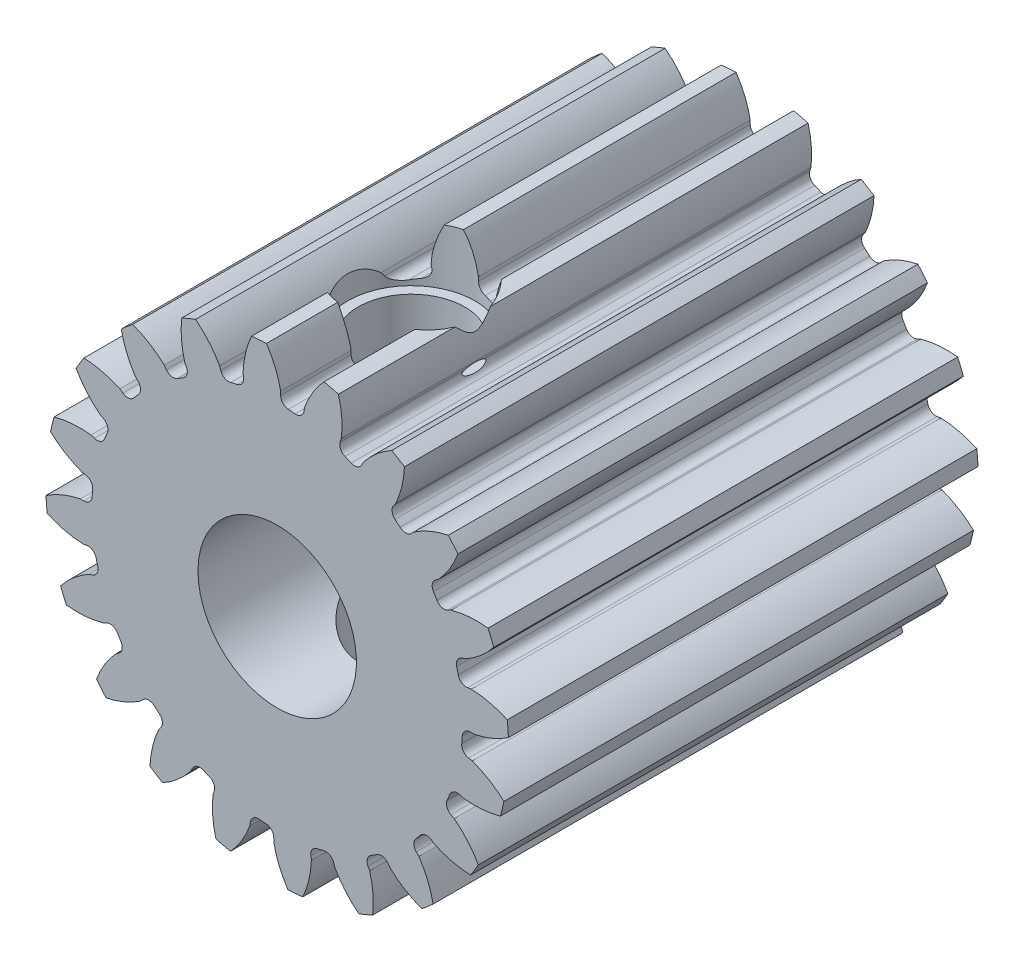
from build123d import *

# Parameters (mm, degrees)
SKETCH1_R                = 8.763
BOSS_EXTRUDE1_DEPTH      = 304.8
CUT_EXTRUDE1_DEPTH       = 305.8
FILLET1_R                = 0.311705625
CIRPATTERN1_COUNT        = 20
FILLET1_OF_CIRPATTERN1_R = 0.311705625
CUT_EXTRUDE2_START       = 6.604
SKETCH6_R                = 2.413
CUT_EXTRUDE2_DEPTH       = 3.149595983
F_10_32_TAPPED_HOLE1_D   = 4.0386


with BuildPart() as part:
    # Sketch1 → Boss-Extrude1 (new body)
    with BuildSketch(Plane.XY):
        Circle(SKETCH1_R)
    extrude(amount=-BOSS_EXTRUDE1_DEPTH)

    # Sketch4 → Cut-Extrude1 (cut, through all)
    with BuildSketch(Plane.XY):
        with BuildLine():
            Line((0.129659117, 7.457683137), (0.129659117, 7.0179336))
            ThreePointArc((0.129659117, 7.0179336), (0.550715976, 6.99749351), (0.969786444, 6.95181399))
            Line((0.969786444, 6.95181399), (1.038578587, 7.386149456))
            add(Edge.make_bspline(
                [(2.617270175, 9.278720795), (1.469881899, 8.555671015), (1.038578587, 7.386149456)],
                knots=[0, 0, 0, 1, 1, 1], degree=2))
            ThreePointArc((2.617270175, 9.278720795), (0.75640915, 9.611066952), (-1.133531995, 9.573916021))
            add(Edge.make_bspline(
                [(-1.133531995, 9.573916021), (-0.113380207, 8.680276738), (0.129659117, 7.457683137)],
                knots=[0, 0, 0, 1, 1, 1], degree=2))
        make_face()
    cut_extrude1 = extrude(amount=-CUT_EXTRUDE1_DEPTH, mode=Mode.SUBTRACT)

    # Fillet1
    fillet1_edges = [part.edges().sort_by_distance(p)[0] for p in [
        (0.969786444, 6.95181399, -152.4),
        (0.129659117, 7.0179336, -152.4),
    ]]
    fillet(fillet1_edges, radius=FILLET1_R)

    # CirPattern1: Cut-Extrude1 ×20 about axis
    cirpattern1_axis = Axis((0, 0, -304.8), (0, 0, 1))
    for i in range(1, CIRPATTERN1_COUNT):
        add(cut_extrude1.rotate(cirpattern1_axis, i * 360 / CIRPATTERN1_COUNT), mode=Mode.SUBTRACT)

    # Fillet1 of CirPattern1
    fillet1_of_cirpattern1_edges = [part.edges().sort_by_distance(p)[0] for p in [
        (-1.225906948, 6.911248488, -152.4),
        (-2.0453476, 6.714518352, -152.4),
        (-3.301600026, 6.19416183, -152.4),
        (-4.020141443, 5.753839265, -152.4),
        (-5.05410949, 4.870747454, -152.4),
        (-5.601415831, 4.229934301, -152.4),
        (-6.311887504, 3.070550382, -152.4),
        (-6.634384611, 2.291973896, -152.4),
        (-6.95181399, 0.969786444, -152.4),
        (-7.0179336, 0.129659117, -152.4),
        (-6.911248488, -1.225906948, -152.4),
        (-6.714518352, -2.0453476, -152.4),
        (-6.19416183, -3.301600026, -152.4),
        (-5.753839265, -4.020141443, -152.4),
        (-4.870747454, -5.05410949, -152.4),
        (-4.229934301, -5.601415831, -152.4),
        (-3.070550382, -6.311887504, -152.4),
        (-2.291973896, -6.634384611, -152.4),
        (-0.969786444, -6.95181399, -152.4),
        (-0.129659117, -7.0179336, -152.4),
        (1.225906948, -6.911248488, -152.4),
        (2.0453476, -6.714518352, -152.4),
        (3.301600026, -6.19416183, -152.4),
        (4.020141443, -5.753839265, -152.4),
        (5.05410949, -4.870747454, -152.4),
        (5.601415831, -4.229934301, -152.4),
        (6.311887504, -3.070550382, -152.4),
        (6.634384611, -2.291973896, -152.4),
        (6.95181399, -0.969786444, -152.4),
        (7.0179336, -0.129659117, -152.4),
        (6.911248488, 1.225906948, -152.4),
        (6.714518352, 2.0453476, -152.4),
        (6.19416183, 3.301600026, -152.4),
        (5.753839265, 4.020141443, -152.4),
        (4.870747454, 5.05410949, -152.4),
        (4.229934301, 5.601415831, -152.4),
        (3.070550382, 6.311887504, -152.4),
        (2.291973896, 6.634384611, -152.4),
    ]]
    fillet(fillet1_of_cirpattern1_edges, radius=FILLET1_OF_CIRPATTERN1_R)

    # Sketch5 → Cut-Revolve1 (revolve, cut)
    with BuildSketch(Plane(origin=(0, 0, 0), x_dir=(1, 0, 0), z_dir=(0, 1, 0))):
        Polygon((0, 0), (3, 0), (3, 17.78), (16.5, 17.78), (16.5, 304.8), (0, 304.8), align=None)
    revolve(axis=Axis((0, 0, 0), (0, 0, 1)), mode=Mode.SUBTRACT)

    # Sketch6 → Cut-Extrude2 (cut, through all)
    with BuildSketch(Plane(origin=(0, 0, 0), x_dir=(1, 0, 0), z_dir=(0, 1, 0)).offset(CUT_EXTRUDE2_START)):
        with Locations((0, 5.08)):
            Circle(SKETCH6_R)
    extrude(amount=CUT_EXTRUDE2_DEPTH, mode=Mode.SUBTRACT)

    # #10-32 Tapped Hole1 (through all)
    with Locations(Plane(origin=(0, 6.604, 0), x_dir=(1, 0, 0), z_dir=(0, 1, 0))):
        with Locations((0, 5.08)):
            Hole(F_10_32_TAPPED_HOLE1_D / 2)


solid = part.part
